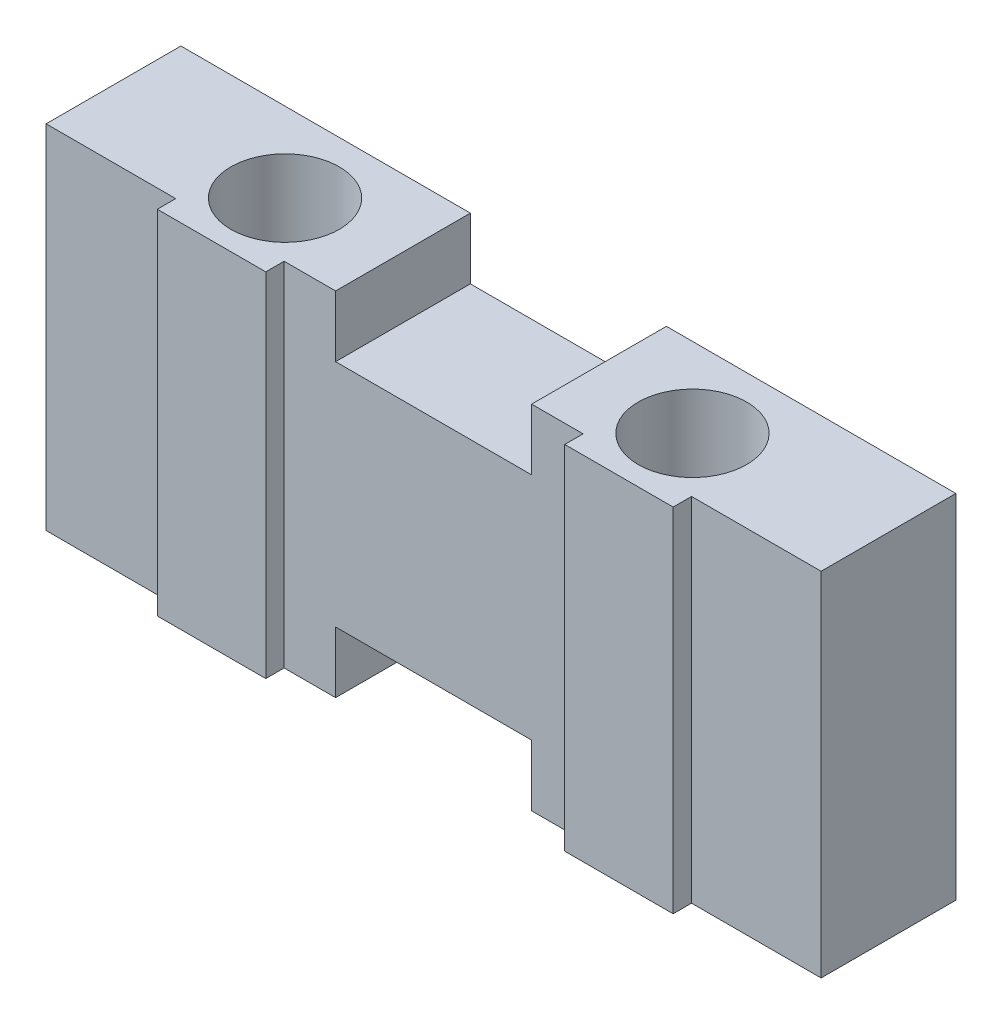
from build123d import *

# Parameters (mm, degrees)
EXTRUDE1_DEPTH     = 2.5
CUT_EXTRUDE1_REACH = 7.75
SKETCH2_R          = 0.885
SKETCH2_W          = 4.04
SKETCH2_H          = 0.3
SKETCH2_W_2        = 0.84
SKETCH2_W_3        = 2.115


with BuildPart() as part:
    # Sketch1 → Extrude1 (new body)
    with BuildSketch(Plane.XY):
        Polygon((-1.6, 1), (1.6, 1), (1.6, 0), (6.325, 0), (6.325, 5.75), (1.6, 5.75), (1.6, 4.75), (-1.6, 4.75), (-1.6, 5.75), (-6.325, 5.75), (-6.325, 0), (-1.6, 0), align=None)
    extrude(amount=EXTRUDE1_DEPTH)

    # Sketch2 → Cut-Extrude1 (cut, up to next)
    with BuildSketch(Plane(origin=(0, 5.75, 0), x_dir=(-1, 0, 0), z_dir=(0, 1, 0)), mode=Mode.PRIVATE) as cut_extrude1_sk1:
        with Locations((3.325, 1.3)):
            Circle(SKETCH2_R)
    cut_extrude1_tool1 = extrude(cut_extrude1_sk1.sketch, amount=-CUT_EXTRUDE1_REACH, mode=Mode.PRIVATE) & part.part
    add(cut_extrude1_tool1.solids().sort_by_distance((-3.325, 5.75, 1.3))[0], mode=Mode.SUBTRACT)
    # Sketch2 → Cut-Extrude1 (cut, up to next)
    with BuildSketch(Plane(origin=(0, 5.75, 0), x_dir=(-1, 0, 0), z_dir=(0, 1, 0)), mode=Mode.PRIVATE) as cut_extrude1_sk2:
        with Locations((-3.325, 1.3)):
            Circle(SKETCH2_R)
    cut_extrude1_tool2 = extrude(cut_extrude1_sk2.sketch, amount=-CUT_EXTRUDE1_REACH, mode=Mode.PRIVATE) & part.part
    add(cut_extrude1_tool2.solids().sort_by_distance((3.325, 5.75, 1.3))[0], mode=Mode.SUBTRACT)
    # Sketch2 → Cut-Extrude1 (cut, up to next)
    with BuildSketch(Plane(origin=(0, 5.75, 0), x_dir=(-1, 0, 0), z_dir=(0, 1, 0)), mode=Mode.PRIVATE) as cut_extrude1_sk3:
        with Locations((-0.42, 2.35)):
            Rectangle(SKETCH2_W, SKETCH2_H)
    cut_extrude1_tool3 = extrude(cut_extrude1_sk3.sketch, amount=-CUT_EXTRUDE1_REACH, mode=Mode.PRIVATE) & part.part
    add(cut_extrude1_tool3.solids().sort_by_distance((0.42, 5.75, 2.35))[0], mode=Mode.SUBTRACT)
    # Sketch2 → Cut-Extrude1 (cut, up to next)
    with BuildSketch(Plane(origin=(0, 5.75, 0), x_dir=(-1, 0, 0), z_dir=(0, 1, 0)), mode=Mode.PRIVATE) as cut_extrude1_sk4:
        with Locations((2.02, 2.35)):
            Rectangle(SKETCH2_W_2, SKETCH2_H)
    cut_extrude1_tool4 = extrude(cut_extrude1_sk4.sketch, amount=-CUT_EXTRUDE1_REACH, mode=Mode.PRIVATE) & part.part
    add(cut_extrude1_tool4.solids().sort_by_distance((-2.02, 5.75, 2.35))[0], mode=Mode.SUBTRACT)
    # Sketch2 → Cut-Extrude1 (cut, up to next)
    with BuildSketch(Plane(origin=(0, 5.75, 0), x_dir=(-1, 0, 0), z_dir=(0, 1, 0)), mode=Mode.PRIVATE) as cut_extrude1_sk5:
        with Locations((-5.2675, 2.35)):
            Rectangle(SKETCH2_W_3, SKETCH2_H)
    cut_extrude1_tool5 = extrude(cut_extrude1_sk5.sketch, amount=-CUT_EXTRUDE1_REACH, mode=Mode.PRIVATE) & part.part
    add(cut_extrude1_tool5.solids().sort_by_distance((5.2675, 5.75, 2.35))[0], mode=Mode.SUBTRACT)
    # Sketch2 → Cut-Extrude1 (cut, up to next)
    with BuildSketch(Plane(origin=(0, 5.75, 0), x_dir=(-1, 0, 0), z_dir=(0, 1, 0)), mode=Mode.PRIVATE) as cut_extrude1_sk6:
        with Locations((5.2675, 2.35)):
            Rectangle(SKETCH2_W_3, SKETCH2_H)
    cut_extrude1_tool6 = extrude(cut_extrude1_sk6.sketch, amount=-CUT_EXTRUDE1_REACH, mode=Mode.PRIVATE) & part.part
    add(cut_extrude1_tool6.solids().sort_by_distance((-5.2675, 5.75, 2.35))[0], mode=Mode.SUBTRACT)


solid = part.part
